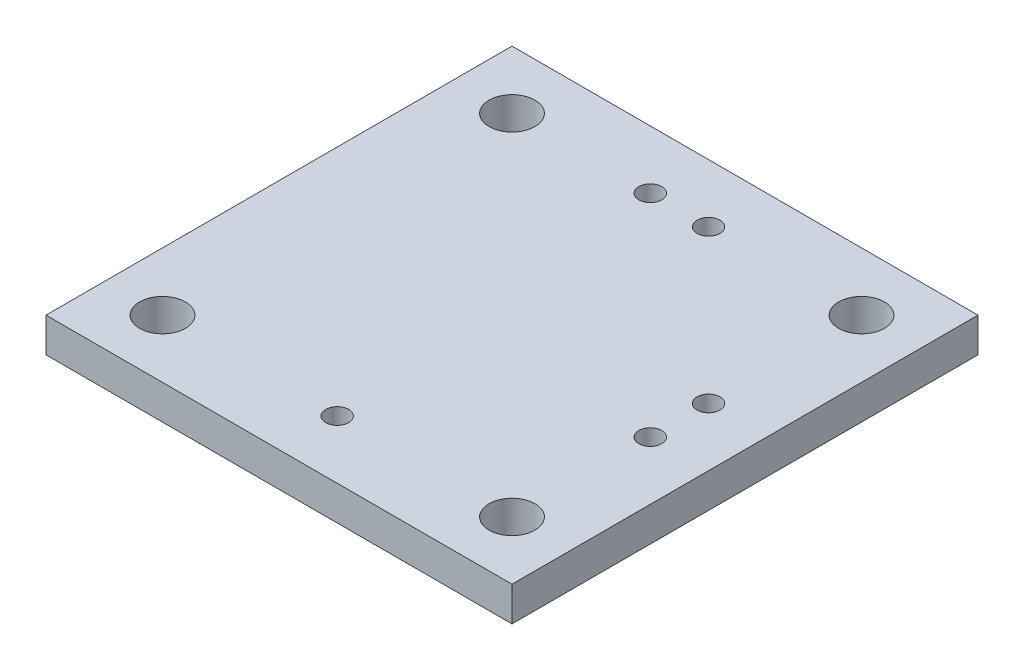
from build123d import *

# Parameters (mm, degrees)
SKETCH1_W           = 20.32
SKETCH1_H           = 20.32
SKETCH1_R           = 1
SKETCH1_R_2         = 0.5
BOSS_EXTRUDE1_DEPTH = 1.5
CUT_EXTRUDE1_START  = 1.5
SKETCH1_3_R         = 0.5
CUT_EXTRUDE1_DEPTH  = 0.762


with BuildPart() as part:
    # Sketch1 → Boss-Extrude1 (new body)
    with BuildSketch(Plane(origin=(0, 0, 0), x_dir=(1, 0, 0), z_dir=(0, 1, 0))):
        with Locations((10.16, 10.16)):
            Rectangle(SKETCH1_W, SKETCH1_H)
        with Locations(Location((2.54, 2.54, 0), (0, 0, 270))):  # turned: the seam where the file's is
            Circle(SKETCH1_R, mode=Mode.SUBTRACT)
        with Locations(Location((17.78, 2.54, 0), (0, 0, 270))):  # turned: the seam where the file's is
            Circle(SKETCH1_R, mode=Mode.SUBTRACT)
        with Locations(Location((17.78, 17.78, 0), (0, 0, 270))):  # turned: the seam where the file's is
            Circle(SKETCH1_R, mode=Mode.SUBTRACT)
        with Locations(Location((2.54, 17.78, 0), (0, 0, 270))):  # turned: the seam where the file's is
            Circle(SKETCH1_R, mode=Mode.SUBTRACT)
        with Locations(Location((10.16, 2.54, 0), (0, 0, 270))):  # turned: the seam where the file's is
            Circle(SKETCH1_R_2, mode=Mode.SUBTRACT)
    extrude(amount=BOSS_EXTRUDE1_DEPTH)

    # Sketch1_3 → Cut-Extrude1 (cut)
    with BuildSketch(Plane(origin=(0, 0, 0), x_dir=(1, 0, 0), z_dir=(0, 1, 0)).offset(CUT_EXTRUDE1_START)):
        with Locations(Location((17.78, 11.11, 0), (0, 0, 270))):  # turned: the seam where the file's is
            Circle(SKETCH1_3_R)
        with Locations(Location((17.78, 8.57, 0), (0, 0, 270))):  # turned: the seam where the file's is
            Circle(SKETCH1_3_R)
        with Locations(Location((11.109999878, 17.78, 0), (0, 0, 90))):  # turned: the seam where the file's is
            Circle(SKETCH1_3_R)
        with Locations(Location((8.569999878, 17.78, 0), (0, 0, 270))):  # turned: the seam where the file's is
            Circle(SKETCH1_3_R)
    extrude(amount=-CUT_EXTRUDE1_DEPTH, mode=Mode.SUBTRACT)


solid = part.part
